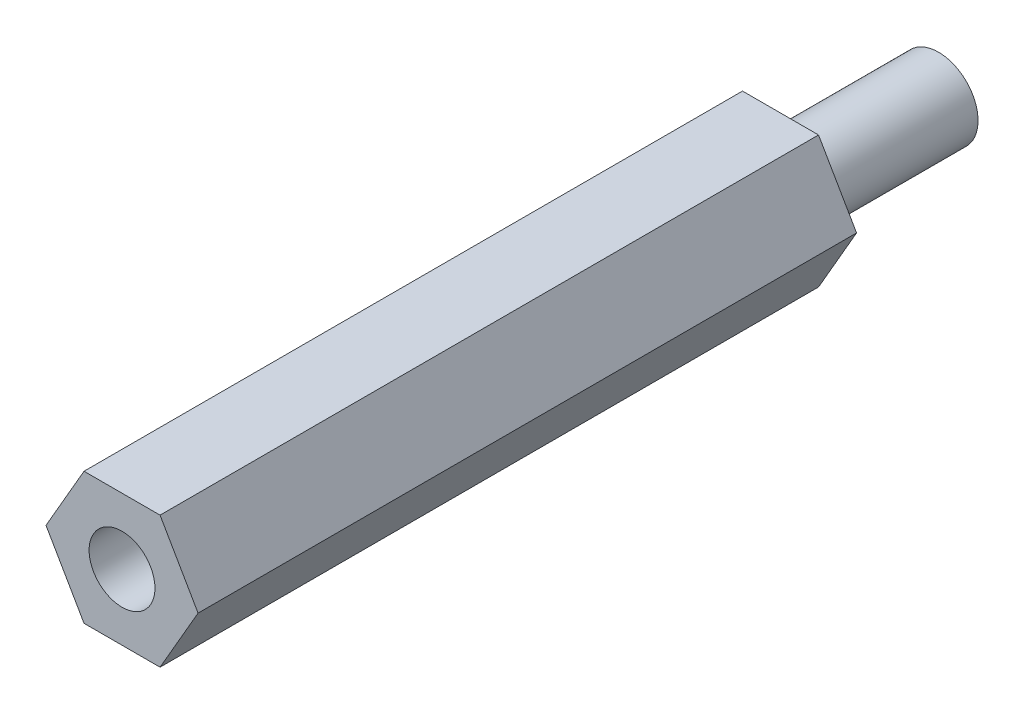
from build123d import *

# Parameters (mm, degrees)
EXTRUDE_1_DEPTH = 25
SKETCH_4_R      = 1.5
EXTRUDE_2_DEPTH = 6
M3X0_5_1_D      = 2.5
M3X0_5_1_DEPTH  = 7.5
M3X0_5_1_TIP    = 0.751075774


with BuildPart() as part:
    # 草圖1 → 填料-伸長1 (new body)
    with BuildSketch(Plane.XY):
        Polygon((-1.443375673, 2.5), (-2.886751346, 0), (-1.443375673, -2.5), (1.443375673, -2.5), (2.886751346, 0), (1.443375673, 2.5), align=None)
    extrude(amount=EXTRUDE_1_DEPTH)

    # 草圖4 → 填料-伸長2 (add)
    with BuildSketch(Plane(origin=(0, 0, 0), x_dir=(-1, 0, 0), z_dir=(0, 0, -1))):
        Circle(SKETCH_4_R)
    extrude(amount=EXTRUDE_2_DEPTH)

    # M3x0.5 螺紋孔1
    with Locations(Plane.XY.offset(25)):
        with Locations((0, 0)):
            Hole(M3X0_5_1_D / 2, depth=M3X0_5_1_DEPTH)
            with Locations((0, 0, -(M3X0_5_1_DEPTH + M3X0_5_1_TIP / 2))):  # 118° drill point
                Cone(0, M3X0_5_1_D / 2, M3X0_5_1_TIP, mode=Mode.SUBTRACT)


solid = part.part
